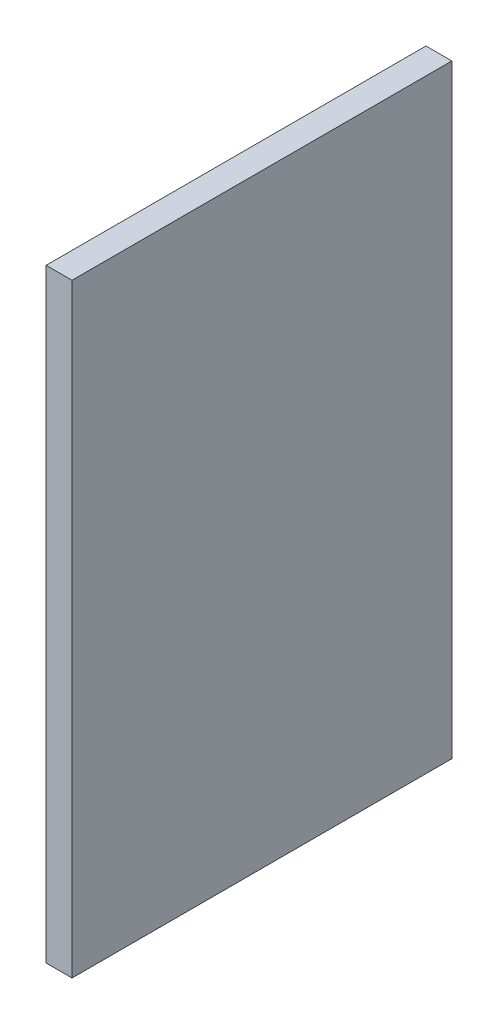
from build123d import *

# Parameters (mm, degrees)
ESQUISSE1_W        = 220
ESQUISSE1_H        = 350
BOSS_EXTRU_1_DEPTH = 15


with BuildPart() as part:
    # Esquisse1 → Boss.-Extru.1 (new body)
    with BuildSketch(Plane(origin=(0, 0, 0), x_dir=(0, 0, -1), z_dir=(1, 0, 0))):
        Rectangle(ESQUISSE1_W, ESQUISSE1_H)
    extrude(amount=BOSS_EXTRU_1_DEPTH)


solid = part.part
